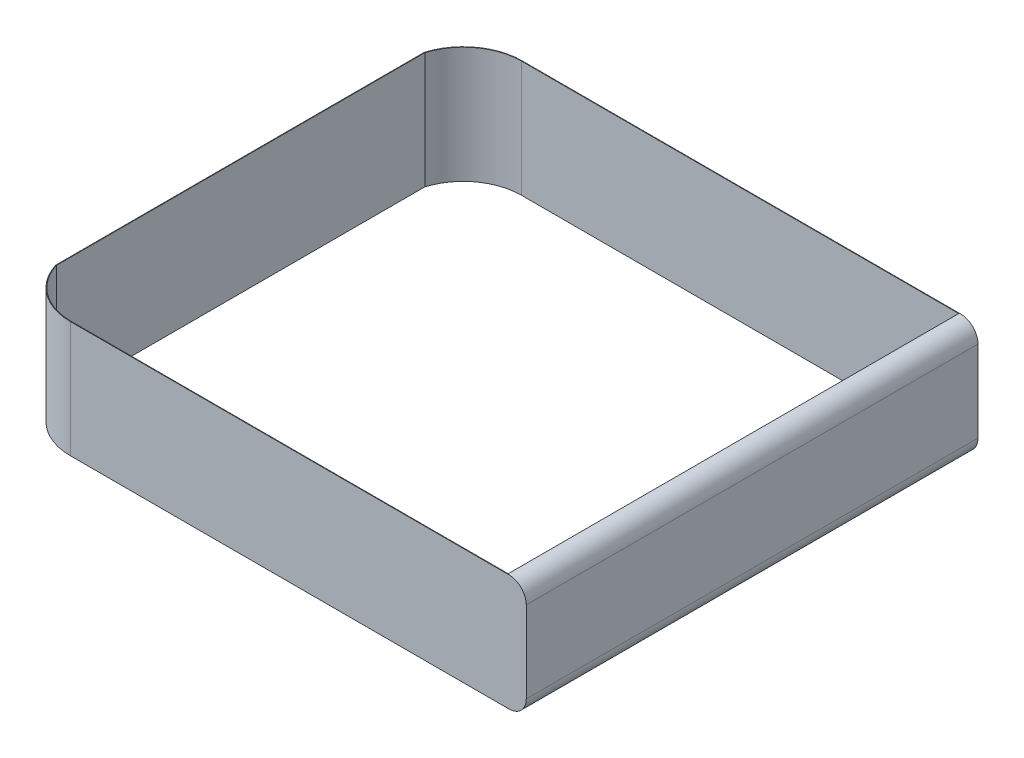
from build123d import *

# Parameters (mm, degrees)
EXTRUDE_THIN1_DEPTH = 1976
BOSS_EXTRUDE1_DEPTH = 7680


with BuildPart() as part:
    # Sketch3 → Extrude-Thin1 (new body)
    with BuildSketch(Plane(origin=(0, 0, 0), x_dir=(1, 0, 0), z_dir=(0, 1, 0))):
        with BuildLine():
            Line((8389.704370421, -8680), (955.264370754, -8680))
            ThreePointArc((955.264370754, -8680), (361.265893237, -8484.261451204), (0, -7973.737480011))
            Line((0, -7973.737480011), (0, -1706.262519989))
            ThreePointArc((0, -1706.262519989), (361.265893237, -1195.738548796), (955.264370754, -1000))
            Line((955.264370754, -1000), (8389.704370421, -1000))
            Line((8389.704370421, -1000), (8389.704370421, -1010))
            Line((8389.704370421, -1010), (955.264370754, -1010))
            ThreePointArc((955.264370754, -1010), (367.812088707, -1203.335369926), (10, -1707.76500637))
            Line((10, -1707.76500637), (10, -7972.23499363))
            ThreePointArc((10, -7972.23499363), (367.812088707, -8476.664630074), (955.264370754, -8670))
            Line((955.264370754, -8670), (8389.704370421, -8670))
            Line((8389.704370421, -8670), (8389.704370421, -8680))
        make_face()
    extrude(amount=EXTRUDE_THIN1_DEPTH)

    # Sketch6 → Boss-Extrude1 (add)
    with BuildSketch(Plane(origin=(0, 0, 1000), x_dir=(-1, 0, 0), z_dir=(0, 0, -1))):
        with BuildLine():
            Line((-8706.667783767, 1679.867153644), (-8706.667783767, 296.132846356))
            ThreePointArc((-8706.667783767, 296.132846356), (-8612.48413892, 79.245509191), (-8389.704370421, 0))
            Line((-8389.704370421, 0), (-8389.704370421, 1976))
            ThreePointArc((-8389.704370421, 1976), (-8612.48413892, 1896.754490809), (-8706.667783767, 1679.867153644))
        make_face()
    extrude(amount=-BOSS_EXTRUDE1_DEPTH)


solid = part.part
